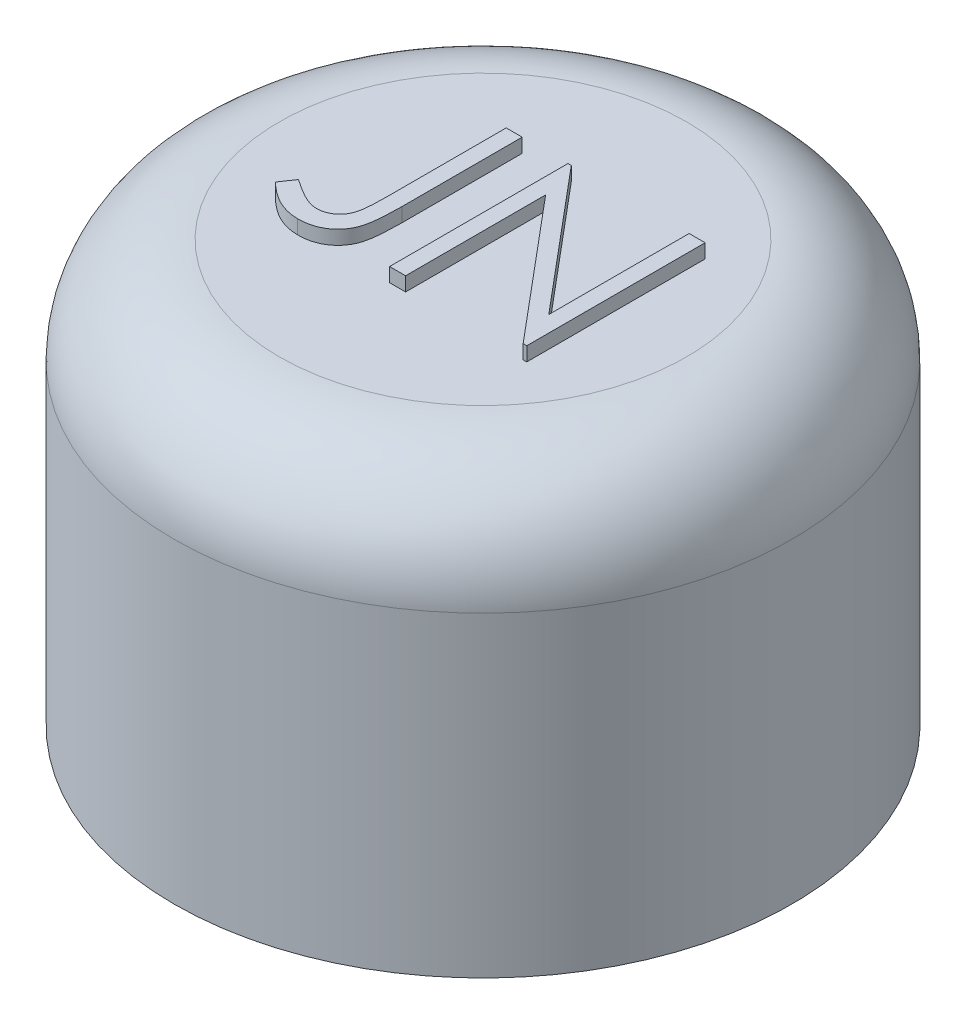
from build123d import *

# Parameters (mm, degrees)
SKETCH2_R           = 22
BOSS_EXTRUDE3_DEPTH = 30
SKETCH1_R           = 4.5
CUT_EXTRUDE2_DEPTH  = 25
FILLET1_R           = 7.5
BOSS_EXTRUDE4_DEPTH = 1


with BuildPart() as part:
    # Sketch2 → Boss-Extrude3 (new body)
    with BuildSketch(Plane(origin=(0, 30, 0), x_dir=(1, 0, 0), z_dir=(0, 1, 0))):
        with Locations(Location((0, 0, 0), (0, 0, 270))):
            Circle(SKETCH2_R)
    extrude(amount=-BOSS_EXTRUDE3_DEPTH)

    # Sketch1 → Cut-Extrude2 (cut)
    with BuildSketch(Plane(origin=(0, 0, 0), x_dir=(1, 0, 0), z_dir=(0, 1, 0))):
        with Locations(Location((0, 13, 0), (0, 0, 270))):
            Circle(SKETCH1_R)
        with Locations(Location((-11.258330249, 6.5, 0), (0, 0, 270))):
            Circle(SKETCH1_R)
        with Locations(Location((-11.258330249, -6.5, 0), (0, 0, 270))):
            Circle(SKETCH1_R)
        with Locations(Location((11.258330249, 6.5, 0), (0, 0, 270))):
            Circle(SKETCH1_R)
        with Locations(Location((11.258330249, -6.5, 0), (0, 0, 270))):
            Circle(SKETCH1_R)
        with Locations(Location((0, -13, 0), (0, 0, 270))):
            Circle(SKETCH1_R)
    extrude(amount=CUT_EXTRUDE2_DEPTH, mode=Mode.SUBTRACT)

    # Fillet1
    fillet1_edges = [part.edges().sort_by_distance(p)[0] for p in [
        (0, 30, -22),
    ]]
    fillet(fillet1_edges, radius=FILLET1_R)

    # Sketch3 → Boss-Extrude4 (add)
    with BuildSketch(Plane(origin=(0, 30, 0), x_dir=(1, 0, 0), z_dir=(0, 1, 0))):
        with BuildLine():
            Line((-5.047435897, 6.7), (-3.907692308, 6.7))
            Line((-3.907692308, 6.7), (-3.907692308, -1.876061699))
            add(Edge.make_bspline(
                [(-3.907692308, -1.876061699), (-3.908831384, -2.034649033), (-3.911018549, -2.339156067), (-3.923045124, -2.777755632), (-3.945300887, -3.17824355), (-3.977722218, -3.541530486), (-4.020975634, -3.86647833), (-4.070473079, -4.155597886), (-4.130390949, -4.406476162), (-4.220620698, -4.688181596), (-4.368571883, -4.997131973), (-4.591246564, -5.330797805), (-4.867862712, -5.622656181), (-5.188269318, -5.876121783), (-5.555266748, -6.078078021), (-5.961297429, -6.22305824), (-6.403861903, -6.311489634), (-6.710836188, -6.320829233), (-6.868990385, -6.325641026)],
                knots=[0, 0, 0, 0, 1.237770943, 2.376671248, 3.424123796, 4.367912054, 5.222547132, 5.982086412, 6.656319012, 7.234008312, 8.288027371, 9.317870876, 10.352700517, 11.413286737, 12.494591526, 13.606319346, 14.766767577, 16, 16, 16, 16], degree=3))
            add(Edge.make_bspline(
                [(-6.868990385, -6.325641026), (-6.992210713, -6.321719958), (-7.240138175, -6.313830511), (-7.609130176, -6.249526009), (-7.977074488, -6.150407795), (-8.345924031, -6.00525552), (-8.722966135, -5.80784092), (-9.113307336, -5.549541728), (-9.521968629, -5.230838761), (-9.791147982, -4.987587513), (-9.932051282, -4.86025641)],
                knots=[0, 0, 0, 0, 0.848567217, 1.707373443, 2.573483905, 3.470863513, 4.432650262, 5.500696352, 6.691726801, 8, 8, 8, 8], degree=3))
            Line((-9.932051282, -4.86025641), (-9.260416667, -3.883333333))
            add(Edge.make_bspline(
                [(-9.260416667, -3.883333333), (-9.105466946, -3.990185314), (-8.812901668, -4.191935786), (-8.38289984, -4.451475164), (-8.00191017, -4.673997908), (-7.75268919, -4.787399035), (-7.637299679, -4.839903846)],
                knots=[0, 0, 0, 0, 1.196737151, 2.259595785, 3.194191475, 4, 4, 4, 4], degree=3))
            add(Edge.make_bspline(
                [(-7.637299679, -4.839903846), (-7.567325178, -4.867333877), (-7.430089597, -4.921130276), (-7.220267165, -4.98116825), (-7.011642317, -5.01397928), (-6.873329542, -5.020080117), (-6.805388622, -5.023076923)],
                knots=[0, 0, 0, 0, 1.051806502, 2.062826769, 3.048436908, 4, 4, 4, 4], degree=3))
            add(Edge.make_bspline(
                [(-6.805388622, -5.023076923), (-6.717639647, -5.019365856), (-6.544192277, -5.012030446), (-6.292137213, -4.947263075), (-6.050989499, -4.848404813), (-5.829393884, -4.703656404), (-5.625158337, -4.531548106), (-5.456637227, -4.323427732), (-5.31614894, -4.092774019), (-5.231604338, -3.8744376), (-5.177739023, -3.675313828), (-5.143551977, -3.492313592), (-5.113657409, -3.278367655), (-5.087598635, -3.033220643), (-5.072342413, -2.756381753), (-5.055225452, -2.448663863), (-5.049037791, -2.109291153), (-5.047986155, -1.872668556), (-5.047435897, -1.748858173)],
                knots=[0, 0, 0, 0, 0.997221856, 1.971139923, 2.944579524, 3.951425367, 4.971190333, 5.972282193, 6.985401279, 8.033996657, 8.624075553, 9.332086008, 10.151144245, 11.082816738, 12.137127781, 13.306538797, 14.590673636, 16, 16, 16, 16], degree=3))
            Line((-5.047435897, -1.748858173), (-5.047435897, 6.7))
        make_face()
        Polygon((-0.651282051, -6), (-0.651282051, 6.7), (-0.412139423, 6.7), (7.978205128, -3.295653045), (7.978205128, 6.7), (9.117948718, 6.7), (9.117948718, -6), (8.858453526, -6), (0.488461538, 3.97275641), (0.488461538, -6), align=None)
    extrude(amount=BOSS_EXTRUDE4_DEPTH)


solid = part.part
